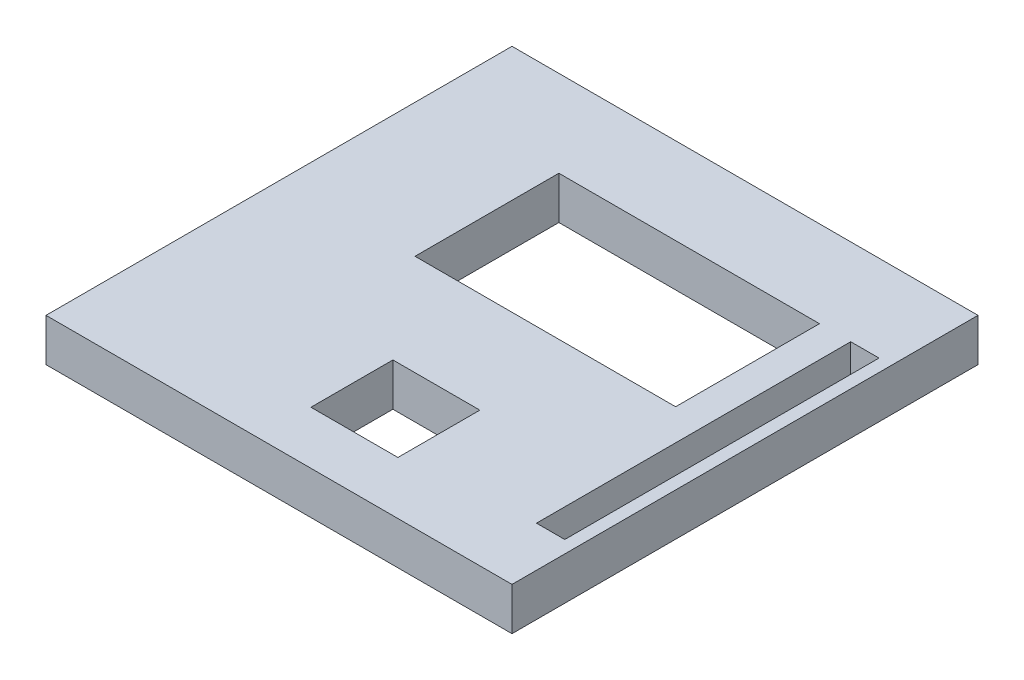
from build123d import *

# Parameters (mm, degrees)
SKETCH2_W           = 120
SKETCH2_H           = 120
BOSS_EXTRUDE1_DEPTH = 11
SKETCH3_W           = 67.10807739
SKETCH3_H           = 37.046087971
SKETCH3_W_2         = 22.393983248
SKETCH3_H_2         = 21.104123885
SKETCH3_W_3         = 7.28775501
SKETCH3_H_3         = 80.924446264
CUT_EXTRUDE1_DEPTH  = 33


with BuildPart() as part:
    # Sketch2 → Boss-Extrude1 (new body)
    with BuildSketch(Plane(origin=(0, 0, 0), x_dir=(1, 0, 0), z_dir=(0, 1, 0))):
        with Locations((5.389221557, -6.467065868)):
            Rectangle(SKETCH2_W, SKETCH2_H)
    extrude(amount=BOSS_EXTRUDE1_DEPTH)

    # Sketch3 → Cut-Extrude1 (cut)
    with BuildSketch(Plane(origin=(0, 11, 0), x_dir=(1, 0, 0), z_dir=(0, 1, 0))):
        with Locations((13.284289485, 12.73920515)):
            Rectangle(SKETCH3_W, SKETCH3_H)
        with Locations((11.196991624, -42.298528004)):
            Rectangle(SKETCH3_W_2, SKETCH3_H_2)
        with Locations((58.529101843, -9.199973997)):
            Rectangle(SKETCH3_W_3, SKETCH3_H_3)
    extrude(amount=-CUT_EXTRUDE1_DEPTH, mode=Mode.SUBTRACT)


solid = part.part
